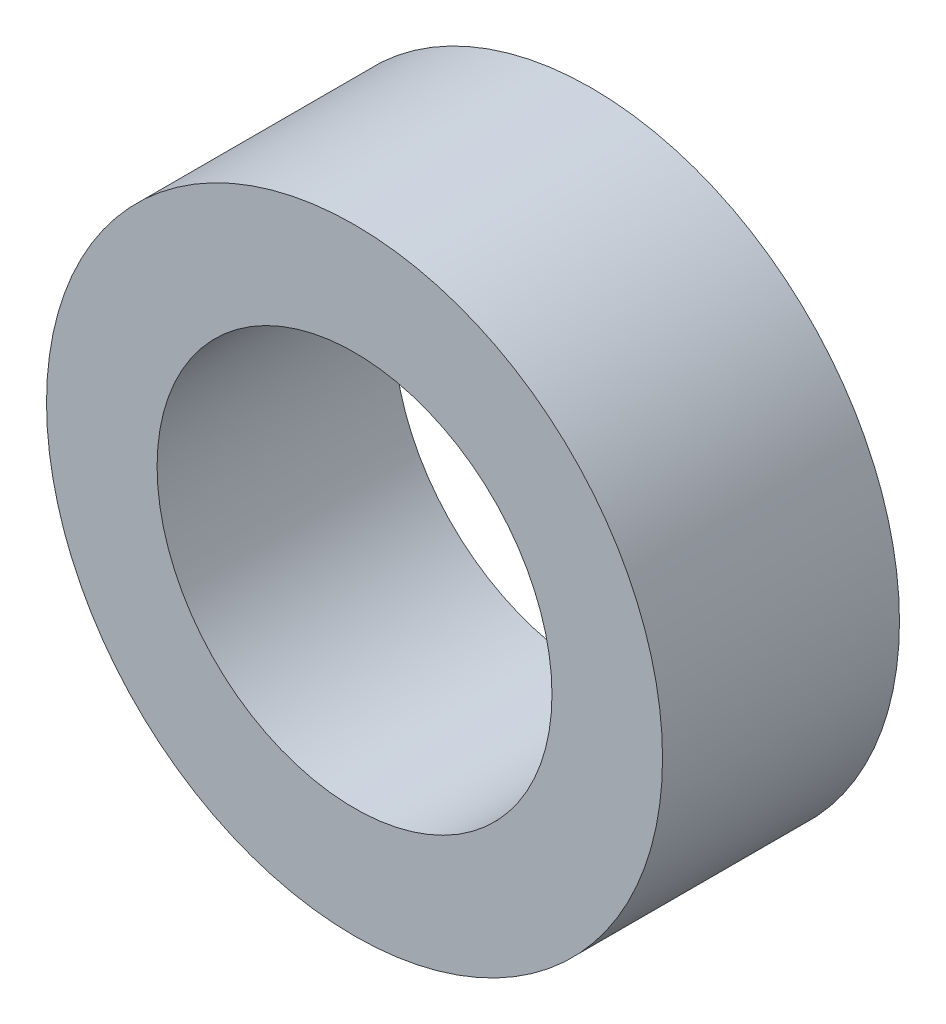
from build123d import *

# Parameters (mm, degrees)
ESQUISSE1_R        = 7.8
ESQUISSE1_R_2      = 5
BOSS_EXTRU_1_DEPTH = 6


with BuildPart() as part:
    # Esquisse1 → Boss.-Extru.1 (new body)
    with BuildSketch(Plane.XY):
        Circle(ESQUISSE1_R)
        Circle(ESQUISSE1_R_2, mode=Mode.SUBTRACT)
    extrude(amount=BOSS_EXTRU_1_DEPTH)


solid = part.part
